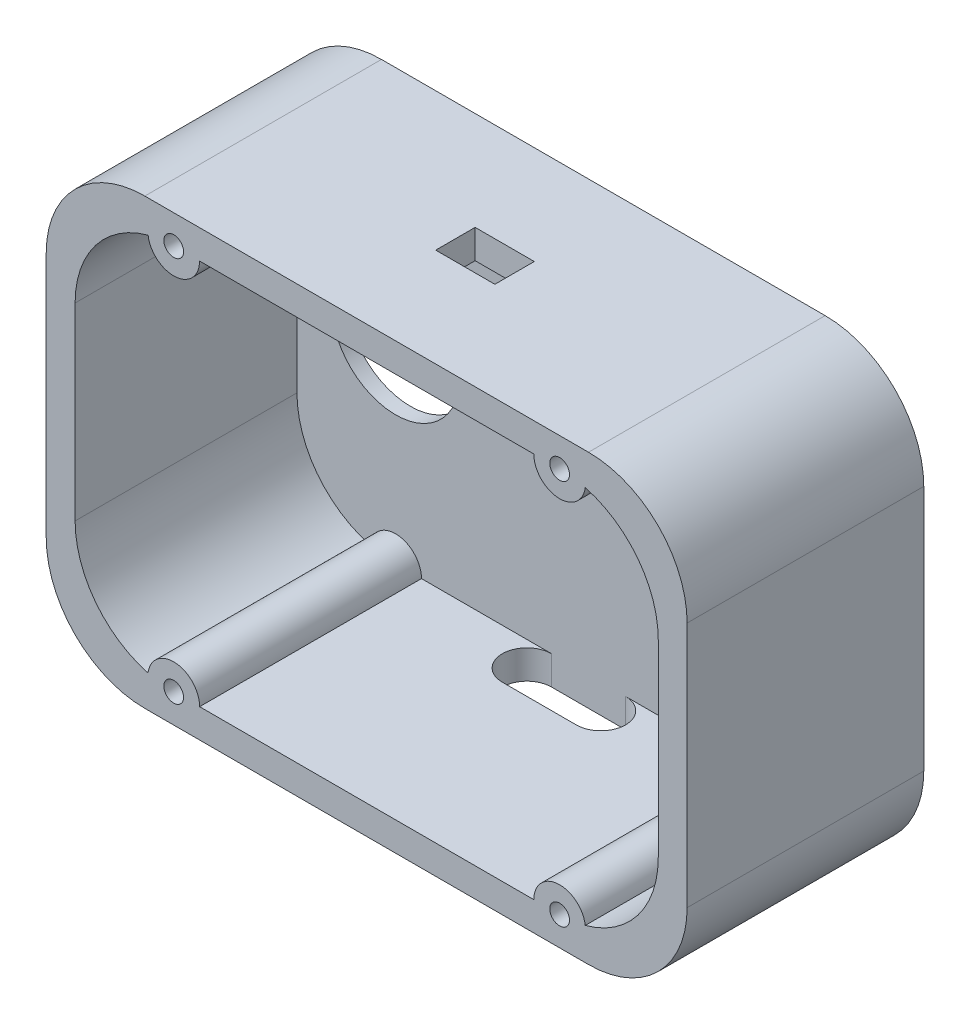
from build123d import *

# Parameters (mm, degrees)
SKETCH1_W           = 130
SKETCH1_H           = 90
BOSS_EXTRUDE1_DEPTH = 48
FILLET1_R           = 20
CUT_EXTRUDE4_DEPTH  = 45
SKETCH3_R           = 5.240734637
SKETCH3_R_2         = 5.258413594
BOSS_EXTRUDE2_DEPTH = 45
CUT_EXTRUDE5_REACH  = 92
SKETCH4_W           = 12
SKETCH4_H           = 8
SKETCH5_R           = 2
CUT_EXTRUDE6_DEPTH  = 23
CUT_EXTRUDE7_DEPTH  = 10
SKETCH7_R           = 13
CUT_EXTRUDE8_DEPTH  = 10
SKETCH8_W           = 10
SKETCH8_H           = 10
CUT_EXTRUDE9_DEPTH  = 30
SKETCH9_W           = 10
SKETCH9_H           = 10
CUT_EXTRUDE10_DEPTH = 10
CUT_EXTRUDE11_DEPTH = 10


with BuildPart() as part:
    # Sketch1 → Boss-Extrude1 (new body)
    with BuildSketch(Plane.XY):
        with Locations((65, 45)):
            Rectangle(SKETCH1_W, SKETCH1_H)
    extrude(amount=BOSS_EXTRUDE1_DEPTH)

    # Fillet1
    fillet1_edges = [part.edges().sort_by_distance(p)[0] for p in [
        (0, 90, 24),
        (130, 90, 24),
        (130, 0, 24),
        (0, 0, 24),
    ]]
    fillet(fillet1_edges, radius=FILLET1_R)

    # Sketch2 → Cut-Extrude4 (cut)
    with BuildSketch(Plane.XY.offset(48)):
        with BuildLine():
            Line((104.142135624, 5.857864376), (25.857864376, 5.857864376))
            ThreePointArc((25.857864376, 5.857864376), (11.715728753, 11.715728753), (5.857864376, 25.857864376))
            Line((5.857864376, 25.857864376), (5.857864376, 64.142135624))
            ThreePointArc((5.857864376, 64.142135624), (11.715728753, 78.284271247), (25.857864376, 84.142135624))
            Line((25.857864376, 84.142135624), (104.142135624, 84.142135624))
            ThreePointArc((104.142135624, 84.142135624), (118.284271247, 78.284271247), (124.142135624, 64.142135624))
            Line((124.142135624, 64.142135624), (124.142135624, 25.857864376))
            ThreePointArc((124.142135624, 25.857864376), (118.284271247, 11.715728753), (104.142135624, 5.857864376))
        make_face()
    extrude(amount=-CUT_EXTRUDE4_DEPTH, mode=Mode.SUBTRACT)

    # Sketch3 → Boss-Extrude2 (add)
    with BuildSketch(Plane.XY.offset(3)):
        with Locations((25.857864376, 84.142135624)):
            Circle(SKETCH3_R)
        with Locations((104.142135624, 84.142135624)):
            Circle(SKETCH3_R)
        with Locations((25.857864376, 5.857864376)):
            Circle(SKETCH3_R_2)
        with Locations((104.142135624, 5.857864376)):
            Circle(SKETCH3_R)
    extrude(amount=BOSS_EXTRUDE2_DEPTH)

    # Sketch4 → Cut-Extrude5 (cut, up to next)
    with BuildSketch(Plane(origin=(0, 90, 0), x_dir=(1, 0, 0), z_dir=(0, 1, 0)), mode=Mode.PRIVATE) as cut_extrude5_sk1:
        with Locations((65, -24)):
            Rectangle(SKETCH4_W, SKETCH4_H)
    cut_extrude5_tool1 = extrude(cut_extrude5_sk1.sketch, amount=-CUT_EXTRUDE5_REACH, mode=Mode.PRIVATE) & part.part
    add(cut_extrude5_tool1.solids().sort_by_distance((65, 90, 24))[0], mode=Mode.SUBTRACT)

    # Sketch5 → Cut-Extrude6 (cut)
    with BuildSketch(Plane.XY.offset(48)):
        with Locations((25.857864376, 84.142135624)):
            Circle(SKETCH5_R)
        with Locations((104.142135624, 84.142135624)):
            Circle(SKETCH5_R)
        with Locations((104.142135624, 5.857864376)):
            Circle(SKETCH5_R)
        with Locations((25.857864376, 5.857864376)):
            Circle(SKETCH5_R)
    extrude(amount=-CUT_EXTRUDE6_DEPTH, mode=Mode.SUBTRACT)

    # Sketch6 → Cut-Extrude7 (cut)
    with BuildSketch(Plane.XY.offset(3)):
        with BuildLine():
            Line((93.401400986, 51.480740698), (93.401400986, 38.519259302))
            ThreePointArc((93.401400986, 38.519259302), (98.901400986, 36.5), (104.401400986, 38.519259302))
            Line((104.401400986, 38.519259302), (104.401400986, 51.480740698))
            ThreePointArc((104.401400986, 51.480740698), (98.901400986, 53.5), (93.401400986, 51.480740698))
        make_face()
    extrude(amount=-CUT_EXTRUDE7_DEPTH, mode=Mode.SUBTRACT)

    # Sketch7 → Cut-Extrude8 (cut)
    with BuildSketch(Plane.XY.offset(3)):
        with Locations((25.857864376, 45)):
            Circle(SKETCH7_R)
    extrude(amount=-CUT_EXTRUDE8_DEPTH, mode=Mode.SUBTRACT)

    # Sketch8 → Cut-Extrude9 (cut)
    with BuildSketch(Plane(origin=(0, 0, 0), x_dir=(-1, 0, 0), z_dir=(0, 0, -1))):
        with Locations((-109.401400986, 65)):
            Rectangle(SKETCH8_W, SKETCH8_H)
        with Locations((-88.401400986, 65)):
            Rectangle(SKETCH8_W, SKETCH8_H)
    extrude(amount=-CUT_EXTRUDE9_DEPTH, mode=Mode.SUBTRACT)

    # Sketch9 → Cut-Extrude10 (cut)
    with BuildSketch(Plane(origin=(0, 0, 0), x_dir=(-1, 0, 0), z_dir=(0, 0, -1))):
        with Locations((-98.901400986, 25)):
            Rectangle(SKETCH9_W, SKETCH9_H)
    extrude(amount=-CUT_EXTRUDE10_DEPTH, mode=Mode.SUBTRACT)

    # Sketch11 → Cut-Extrude11 (cut)
    with BuildSketch(Plane(origin=(0, 5.857864376, 0), x_dir=(1, 0, 0), z_dir=(0, 1, 0))):
        with BuildLine():
            Line((57.508839478, -3), (72.508839478, -3))
            ThreePointArc((72.508839478, -3), (77.508839478, -8), (72.508839478, -13))
            Line((72.508839478, -13), (57.508839478, -13))
            ThreePointArc((57.508839478, -13), (52.508839478, -8), (57.508839478, -3))
        make_face()
    extrude(amount=-CUT_EXTRUDE11_DEPTH, mode=Mode.SUBTRACT)


solid = part.part
